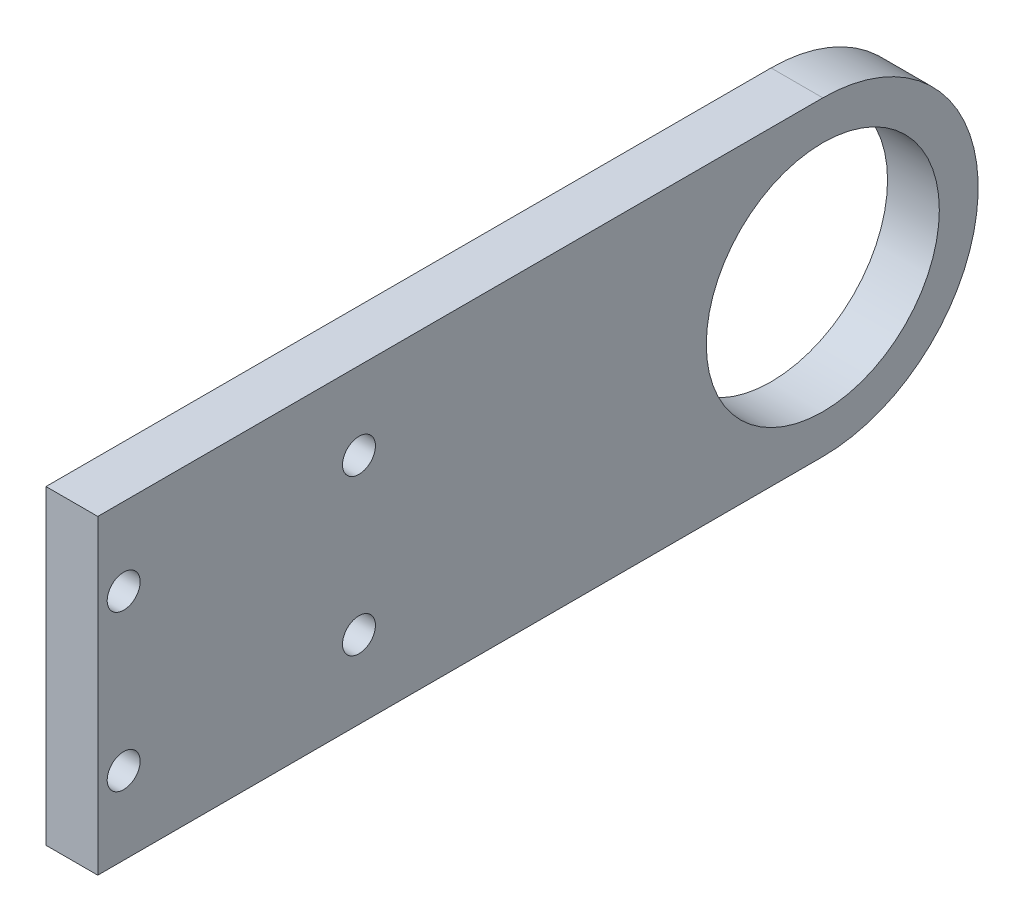
from build123d import *

# Parameters (mm, degrees)
SKETCH2_R           = 14.2875
SKETCH2_R_2         = 2.0193
BOSS_EXTRUDE1_DEPTH = 6.35


with BuildPart() as part:
    # Sketch2 → Boss-Extrude1 (new body)
    with BuildSketch(Plane(origin=(0, 0, 0), x_dir=(0, 0, -1), z_dir=(1, 0, 0))):
        with BuildLine():
            Line((0, 19.05), (0, -19.05))
            Line((0, -19.05), (88.9, -19.05))
            ThreePointArc((88.9, -19.05), (107.95, 0), (88.9, 19.05))
            Line((88.9, 19.05), (0, 19.05))
        make_face()
        with Locations((88.9, 0)):
            Circle(SKETCH2_R, mode=Mode.SUBTRACT)
        with Locations((3.175, -9.525)):
            Circle(SKETCH2_R_2, mode=Mode.SUBTRACT)
        with Locations((3.175, 9.525)):
            Circle(SKETCH2_R_2, mode=Mode.SUBTRACT)
        with Locations((32.025, -9.525)):
            Circle(SKETCH2_R_2, mode=Mode.SUBTRACT)
        with Locations((32.025, 9.525)):
            Circle(SKETCH2_R_2, mode=Mode.SUBTRACT)
    extrude(amount=BOSS_EXTRUDE1_DEPTH)


solid = part.part
